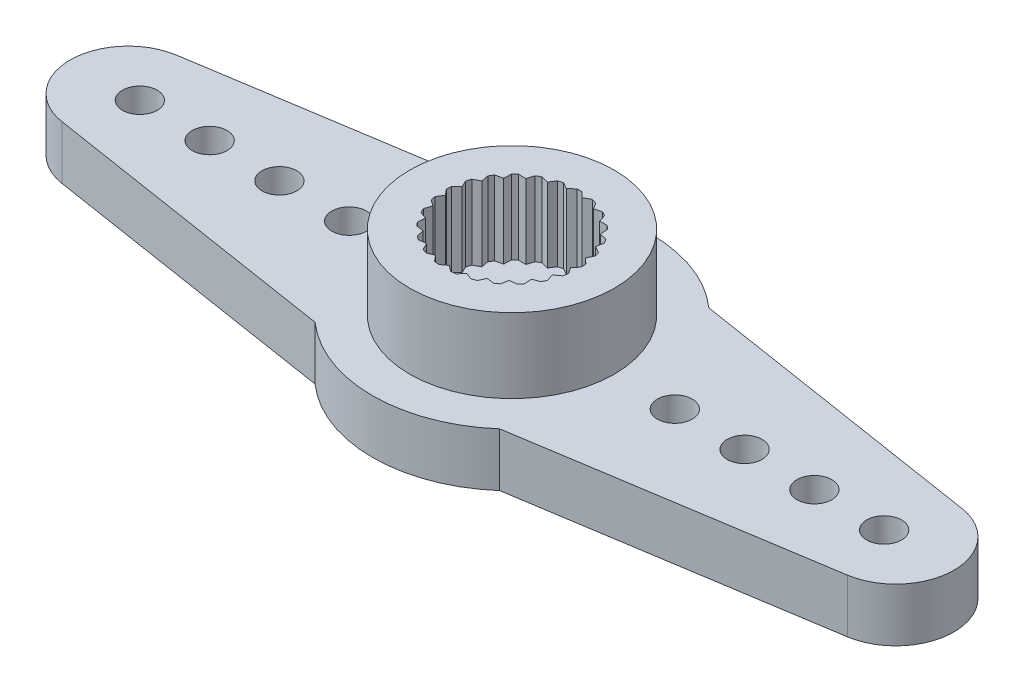
from build123d import *

# Parameters (mm, degrees)
SKETCH2_R           = 6
SKETCH2_R_2         = 1.5
BOSS_EXTRUDE1_DEPTH = 1.15
SKETCH3_R           = 4.4
BOSS_EXTRUDE2_DEPTH = 3.2
SKETCH4_R           = 0.75
BOSS_EXTRUDE3_DEPTH = 1.15
CIRPATTERN1_COUNT   = 2


with BuildPart() as part:
    # Sketch2 → Boss-Extrude1 (new, symmetric)
    with BuildSketch(Plane(origin=(0, 0, 0), x_dir=(1, 0, 0), z_dir=(0, 1, 0))):
        with Locations(Location((0, 0, 0), (0, 0, 270))):
            Circle(SKETCH2_R)
        with Locations(Location((0, 0, 0), (0, 0, 270))):
            Circle(SKETCH2_R_2, mode=Mode.SUBTRACT)
    extrude(amount=BOSS_EXTRUDE1_DEPTH, both=True)

    # Sketch3 → Boss-Extrude2 (add)
    with BuildSketch(Plane(origin=(0, 1.15, 0), x_dir=(1, 0, 0), z_dir=(0, 1, 0))):
        with Locations(Location((0, 0, 0), (0, 0, 270))):
            Circle(SKETCH3_R)
        with BuildLine():
            Line((0.107421435, 2.898009771), (0.338399731, 2.678709694))
            Line((0.338399731, 2.678709694), (0.61665913, 2.83367809))
            ThreePointArc((0.61665913, 2.83367809), (0.721200673, 2.808891167), (0.824752316, 2.780248841))
            Line((0.824752316, 2.780248841), (0.993936292, 2.510396512))
            Line((0.993936292, 2.510396512), (1.301992734, 2.591295993))
            ThreePointArc((1.301992734, 2.591295993), (1.397085655, 2.541289372), (1.490260976, 2.48779465))
            Line((1.490260976, 2.48779465), (1.587020181, 2.184345885))
            Line((1.587020181, 2.184345885), (1.905517346, 2.186093238))
            ThreePointArc((1.905517346, 2.186093238), (1.985186607, 2.11400902), (2.062131058, 2.039023173))
            Line((2.062131058, 2.039023173), (2.080385755, 1.721044772))
            Line((2.080385755, 1.721044772), (2.389311295, 1.643530205))
            ThreePointArc((2.389311295, 1.643530205), (2.448550984, 1.553897705), (2.504429862, 1.46213237))
            Line((2.504429862, 1.46213237), (2.443033042, 1.149604087))
            Line((2.443033042, 1.149604087), (2.722976028, 0.997698125))
            ThreePointArc((2.722976028, 0.997698125), (2.758063897, 0.896149284), (2.789366126, 0.793370413))
            Line((2.789366126, 0.793370413), (2.652175577, 0.505929549))
            Line((2.652175577, 0.505929549), (2.885546163, 0.289177003))
            ThreePointArc((2.885546163, 0.289177003), (2.894277512, 0.182092507), (2.899036259, 0.074758075))
            Line((2.899036259, 0.074758075), (2.694672167, -0.169534403))
            Line((2.694672167, -0.169534403), (2.866806821, -0.437514174))
            ThreePointArc((2.866806821, -0.437514174), (2.848633027, -0.543405812), (2.826549281, -0.648551587))
            Line((2.826549281, -0.648551587), (2.567852594, -0.834345885))
            Line((2.567852594, -0.834345885), (2.667935462, -1.136714727))
            ThreePointArc((2.667935462, -1.136714727), (2.623998452, -1.234759946), (2.576459817, -1.331110368))
            Line((2.576459817, -1.331110368), (2.279685399, -1.446732346))
            Line((2.279685399, -1.446732346), (2.301427906, -1.764491312))
            ThreePointArc((2.301427906, -1.764491312), (2.234488404, -1.84852957), (2.164481907, -1.930030589))
            Line((2.164481907, -1.930030589), (1.848277186, -1.968215294))
            Line((1.848277186, -1.968215294), (1.790313171, -2.281398419))
            ThreePointArc((1.790313171, -2.281398419), (1.704577232, -2.346149284), (1.616501638, -2.40767989))
            Line((1.616501638, -2.40767989), (1.30073492, -2.366028036))
            Line((1.30073492, -2.366028036), (1.166706475, -2.654956874))
            ThreePointArc((1.166706475, -2.654956874), (1.067561203, -2.696351809), (0.966950626, -2.734045809))
            Line((0.966950626, -2.734045809), (0.671462695, -2.615174535))
            Line((0.671462695, -2.615174535), (0.469791321, -2.861694623))
            ThreePointArc((0.469791321, -2.861694623), (0.363466377, -2.877132634), (0.25664255, -2.888621575))
            Line((0.25664255, -2.888621575), (0, -2.7))
            Line((0, -2.7), (-0.25664255, -2.888621575))
            ThreePointArc((-0.25664255, -2.888621575), (-0.363466377, -2.877132634), (-0.469791321, -2.861694623))
            Line((-0.469791321, -2.861694623), (-0.671462695, -2.615174535))
            Line((-0.671462695, -2.615174535), (-0.966950626, -2.734045809))
            ThreePointArc((-0.966950626, -2.734045809), (-1.067561203, -2.696351809), (-1.166706475, -2.654956874))
            Line((-1.166706475, -2.654956874), (-1.30073492, -2.366028036))
            Line((-1.30073492, -2.366028036), (-1.616501638, -2.40767989))
            ThreePointArc((-1.616501638, -2.40767989), (-1.704577232, -2.346149284), (-1.790313171, -2.281398419))
            Line((-1.790313171, -2.281398419), (-1.848277186, -1.968215294))
            Line((-1.848277186, -1.968215294), (-2.164481907, -1.930030589))
            ThreePointArc((-2.164481907, -1.930030589), (-2.234488404, -1.84852957), (-2.301427906, -1.764491312))
            Line((-2.301427906, -1.764491312), (-2.279685399, -1.446732346))
            Line((-2.279685399, -1.446732346), (-2.576459817, -1.331110368))
            ThreePointArc((-2.576459817, -1.331110368), (-2.623998452, -1.234759946), (-2.667935462, -1.136714727))
            Line((-2.667935462, -1.136714727), (-2.567852594, -0.834345885))
            Line((-2.567852594, -0.834345885), (-2.826549281, -0.648551587))
            ThreePointArc((-2.826549281, -0.648551587), (-2.848633027, -0.543405812), (-2.866806821, -0.437514174))
            Line((-2.866806821, -0.437514174), (-2.694672167, -0.169534403))
            Line((-2.694672167, -0.169534403), (-2.899036259, 0.074758075))
            ThreePointArc((-2.899036259, 0.074758075), (-2.894277512, 0.182092507), (-2.885546163, 0.289177003))
            Line((-2.885546163, 0.289177003), (-2.652175577, 0.505929549))
            Line((-2.652175577, 0.505929549), (-2.789366126, 0.793370413))
            ThreePointArc((-2.789366126, 0.793370413), (-2.758063897, 0.896149284), (-2.722976028, 0.997698125))
            Line((-2.722976028, 0.997698125), (-2.443033042, 1.149604087))
            Line((-2.443033042, 1.149604087), (-2.504429862, 1.46213237))
            ThreePointArc((-2.504429862, 1.46213237), (-2.448550984, 1.553897705), (-2.389311295, 1.643530205))
            Line((-2.389311295, 1.643530205), (-2.080385755, 1.721044772))
            Line((-2.080385755, 1.721044772), (-2.062131058, 2.039023173))
            ThreePointArc((-2.062131058, 2.039023173), (-1.985186607, 2.11400902), (-1.905517346, 2.186093238))
            Line((-1.905517346, 2.186093238), (-1.587020181, 2.184345885))
            Line((-1.587020181, 2.184345885), (-1.490260976, 2.48779465))
            ThreePointArc((-1.490260976, 2.48779465), (-1.397085655, 2.541289372), (-1.301992734, 2.591295993))
            Line((-1.301992734, 2.591295993), (-0.993936292, 2.510396512))
            Line((-0.993936292, 2.510396512), (-0.824752316, 2.780248841))
            ThreePointArc((-0.824752316, 2.780248841), (-0.721200673, 2.808891167), (-0.61665913, 2.83367809))
            Line((-0.61665913, 2.83367809), (-0.338399731, 2.678709694))
            Line((-0.338399731, 2.678709694), (-0.107421435, 2.898009771))
            ThreePointArc((-0.107421435, 2.898009771), (0, 2.9), (0.107421435, 2.898009771))
        make_face(mode=Mode.SUBTRACT)
    extrude(amount=BOSS_EXTRUDE2_DEPTH)

    # Sketch4 → Boss-Extrude3 (add, symmetric)
    with BuildSketch(Plane(origin=(0, 0, 0), x_dir=(1, 0, 0), z_dir=(0, 1, 0))):
        with BuildLine():
            Line((3.968626967, 4.5), (16.888114198, 2.469689731))
            ThreePointArc((16.888114198, 2.469689731), (19, 0), (16.888114198, -2.469689731))
            Line((16.888114198, -2.469689731), (3.968626967, -4.5))
            ThreePointArc((3.968626967, -4.5), (6, 0), (3.968626967, 4.5))
        make_face()
        with Locations(Location((16, 0, 0), (0, 0, 270))):
            Circle(SKETCH4_R, mode=Mode.SUBTRACT)
        with Locations(Location((13, 0, 0), (0, 0, 270))):
            Circle(SKETCH4_R, mode=Mode.SUBTRACT)
        with Locations(Location((10, 0, 0), (0, 0, 270))):
            Circle(SKETCH4_R, mode=Mode.SUBTRACT)
        with Locations(Location((7, 0, 0), (0, 0, 270))):
            Circle(SKETCH4_R, mode=Mode.SUBTRACT)
    boss_extrude3 = extrude(amount=BOSS_EXTRUDE3_DEPTH, both=True)

    # CirPattern1: Boss-Extrude3 ×2 about axis
    cirpattern1_axis = Axis((0, 0, 0), (0, 1, 0))
    for i in range(1, CIRPATTERN1_COUNT):
        add(boss_extrude3.rotate(cirpattern1_axis, i * 360 / CIRPATTERN1_COUNT))


solid = part.part
